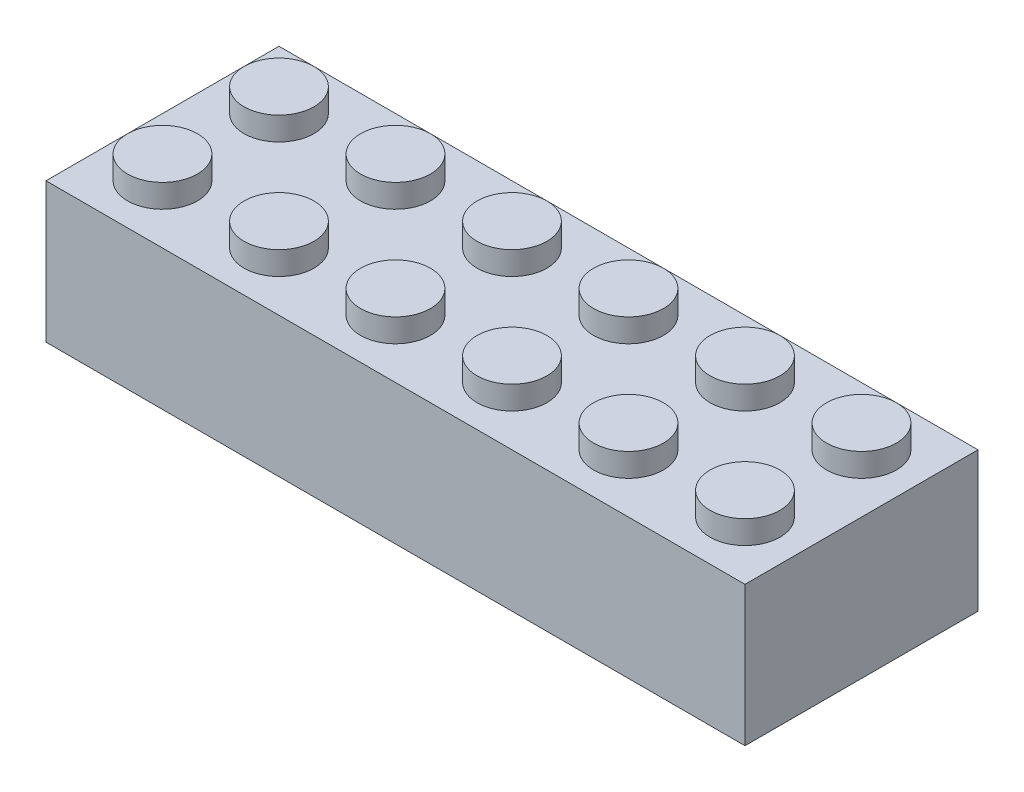
from build123d import *

# Parameters (mm, degrees)
SKETCH1_R              = 1.5
BOSS_EXTRUDE1_DEPTH    = 2
BOSS_EXTRUDE1_2_DEPTH  = 2
BOSS_EXTRUDE1_3_DEPTH  = 2
BOSS_EXTRUDE1_4_DEPTH  = 2
BOSS_EXTRUDE1_5_DEPTH  = 2
BOSS_EXTRUDE1_6_DEPTH  = 2
BOSS_EXTRUDE1_7_DEPTH  = 2
BOSS_EXTRUDE1_8_DEPTH  = 2
BOSS_EXTRUDE1_9_DEPTH  = 2
BOSS_EXTRUDE1_10_DEPTH = 2
BOSS_EXTRUDE1_11_DEPTH = 2
BOSS_EXTRUDE1_12_DEPTH = 2
SKETCH1_3_W            = 30
SKETCH1_3_H            = 10
BOSS_EXTRUDE2_DEPTH    = 1
SKETCH1_4_W            = 30
SKETCH1_4_H            = 10
SKETCH1_4_W_2          = 28
SKETCH1_4_H_2          = 8
SKETCH1_4_R            = 2.035533906
SKETCH1_4_R_2          = 1.5
BOSS_EXTRUDE3_DEPTH    = 5


with BuildPart() as part:
    # Sketch1 → Boss-Extrude1 (new body)
    with BuildSketch(Plane(origin=(0, 0, 0), x_dir=(1, 0, 0), z_dir=(0, 1, 0))):
        with Locations((-12.5, 2.5)):
            Circle(SKETCH1_R)
    extrude(amount=BOSS_EXTRUDE1_DEPTH)



with BuildPart() as body_2:
    # Sketch1 → Boss-Extrude1 2 (new body)
    with BuildSketch(Plane(origin=(0, 0, 0), x_dir=(1, 0, 0), z_dir=(0, 1, 0))):
        with Locations((-7.5, 2.5)):
            Circle(SKETCH1_R)
    extrude(amount=BOSS_EXTRUDE1_2_DEPTH)


with BuildPart() as body_3:
    # Sketch1 → Boss-Extrude1 3 (new body)
    with BuildSketch(Plane(origin=(0, 0, 0), x_dir=(1, 0, 0), z_dir=(0, 1, 0))):
        with Locations((-12.5, -2.5)):
            Circle(SKETCH1_R)
    extrude(amount=BOSS_EXTRUDE1_3_DEPTH)


with BuildPart() as body_4:
    # Sketch1 → Boss-Extrude1 4 (new body)
    with BuildSketch(Plane(origin=(0, 0, 0), x_dir=(1, 0, 0), z_dir=(0, 1, 0))):
        with Locations((-2.5, 2.5)):
            Circle(SKETCH1_R)
    extrude(amount=BOSS_EXTRUDE1_4_DEPTH)


with BuildPart() as body_5:
    # Sketch1 → Boss-Extrude1 5 (new body)
    with BuildSketch(Plane(origin=(0, 0, 0), x_dir=(1, 0, 0), z_dir=(0, 1, 0))):
        with Locations((2.5, 2.5)):
            Circle(SKETCH1_R)
    extrude(amount=BOSS_EXTRUDE1_5_DEPTH)


with BuildPart() as body_6:
    # Sketch1 → Boss-Extrude1 6 (new body)
    with BuildSketch(Plane(origin=(0, 0, 0), x_dir=(1, 0, 0), z_dir=(0, 1, 0))):
        with Locations((-7.5, -2.5)):
            Circle(SKETCH1_R)
    extrude(amount=BOSS_EXTRUDE1_6_DEPTH)


with BuildPart() as body_7:
    # Sketch1 → Boss-Extrude1 7 (new body)
    with BuildSketch(Plane(origin=(0, 0, 0), x_dir=(1, 0, 0), z_dir=(0, 1, 0))):
        with Locations((7.5, 2.5)):
            Circle(SKETCH1_R)
    extrude(amount=BOSS_EXTRUDE1_7_DEPTH)


with BuildPart() as body_8:
    # Sketch1 → Boss-Extrude1 8 (new body)
    with BuildSketch(Plane(origin=(0, 0, 0), x_dir=(1, 0, 0), z_dir=(0, 1, 0))):
        with Locations((-2.5, -2.5)):
            Circle(SKETCH1_R)
    extrude(amount=BOSS_EXTRUDE1_8_DEPTH)


with BuildPart() as body_9:
    # Sketch1 → Boss-Extrude1 9 (new body)
    with BuildSketch(Plane(origin=(0, 0, 0), x_dir=(1, 0, 0), z_dir=(0, 1, 0))):
        with Locations((12.5, 2.5)):
            Circle(SKETCH1_R)
    extrude(amount=BOSS_EXTRUDE1_9_DEPTH)


with BuildPart() as body_10:
    # Sketch1 → Boss-Extrude1 10 (new body)
    with BuildSketch(Plane(origin=(0, 0, 0), x_dir=(1, 0, 0), z_dir=(0, 1, 0))):
        with Locations((2.5, -2.5)):
            Circle(SKETCH1_R)
    extrude(amount=BOSS_EXTRUDE1_10_DEPTH)


with BuildPart() as body_11:
    # Sketch1 → Boss-Extrude1 11 (new body)
    with BuildSketch(Plane(origin=(0, 0, 0), x_dir=(1, 0, 0), z_dir=(0, 1, 0))):
        with Locations((7.5, -2.5)):
            Circle(SKETCH1_R)
    extrude(amount=BOSS_EXTRUDE1_11_DEPTH)


with BuildPart() as body_12:
    # Sketch1 → Boss-Extrude1 12 (new body)
    with BuildSketch(Plane(origin=(0, 0, 0), x_dir=(1, 0, 0), z_dir=(0, 1, 0))):
        with Locations((12.5, -2.5)):
            Circle(SKETCH1_R)
    extrude(amount=BOSS_EXTRUDE1_12_DEPTH)


with BuildPart() as part_1:
    add(part.part)

    add(body_2.part)  # Boss-Extrude2 merges body 2

    add(body_3.part)  # Boss-Extrude2 merges body 3

    add(body_4.part)  # Boss-Extrude2 merges body 4

    add(body_5.part)  # Boss-Extrude2 merges body 5

    add(body_6.part)  # Boss-Extrude2 merges body 6

    add(body_7.part)  # Boss-Extrude2 merges body 7

    add(body_8.part)  # Boss-Extrude2 merges body 8

    add(body_9.part)  # Boss-Extrude2 merges body 9

    add(body_10.part)  # Boss-Extrude2 merges body 10

    add(body_11.part)  # Boss-Extrude2 merges body 11

    add(body_12.part)  # Boss-Extrude2 merges body 12
    # Sketch1_3 → Boss-Extrude2 (add)
    with BuildSketch(Plane(origin=(0, 0, 0), x_dir=(1, 0, 0), z_dir=(0, 1, 0))):
        Rectangle(SKETCH1_3_W, SKETCH1_3_H)
    extrude(amount=BOSS_EXTRUDE2_DEPTH)

    # Sketch1_4 → Boss-Extrude3 (add)
    # profile 1 of 6: a face of its own
    with BuildSketch(Plane(origin=(0, 0, 0), x_dir=(1, 0, 0), z_dir=(0, 1, 0))):
        Rectangle(SKETCH1_4_W, SKETCH1_4_H)
        Rectangle(SKETCH1_4_W_2, SKETCH1_4_H_2, mode=Mode.SUBTRACT)
    # profile 2 of 6: a face of its own
    with BuildSketch(Plane(origin=(0, 0, 0), x_dir=(1, 0, 0), z_dir=(0, 1, 0))):
        with Locations((-10, 0)):
            Circle(SKETCH1_4_R)
        with Locations((-10, 0)):
            Circle(SKETCH1_4_R_2, mode=Mode.SUBTRACT)
    # profile 3 of 6: a face of its own
    with BuildSketch(Plane(origin=(0, 0, 0), x_dir=(1, 0, 0), z_dir=(0, 1, 0))):
        with Locations((-5, 0)):
            Circle(SKETCH1_4_R)
        with Locations((-5, 0)):
            Circle(SKETCH1_4_R_2, mode=Mode.SUBTRACT)
    # profile 4 of 6: a face of its own
    with BuildSketch(Plane(origin=(0, 0, 0), x_dir=(1, 0, 0), z_dir=(0, 1, 0))):
        Circle(SKETCH1_4_R)
        Circle(SKETCH1_4_R_2, mode=Mode.SUBTRACT)
    # profile 5 of 6: a face of its own
    with BuildSketch(Plane(origin=(0, 0, 0), x_dir=(1, 0, 0), z_dir=(0, 1, 0))):
        with Locations((5, 0)):
            Circle(SKETCH1_4_R)
        with Locations((5, 0)):
            Circle(SKETCH1_4_R_2, mode=Mode.SUBTRACT)
    # profile 6 of 6: a face of its own
    with BuildSketch(Plane(origin=(0, 0, 0), x_dir=(1, 0, 0), z_dir=(0, 1, 0))):
        with Locations((10, 0)):
            Circle(SKETCH1_4_R)
        with Locations((10, 0)):
            Circle(SKETCH1_4_R_2, mode=Mode.SUBTRACT)
    extrude(amount=-BOSS_EXTRUDE3_DEPTH)


solid = part_1.part
